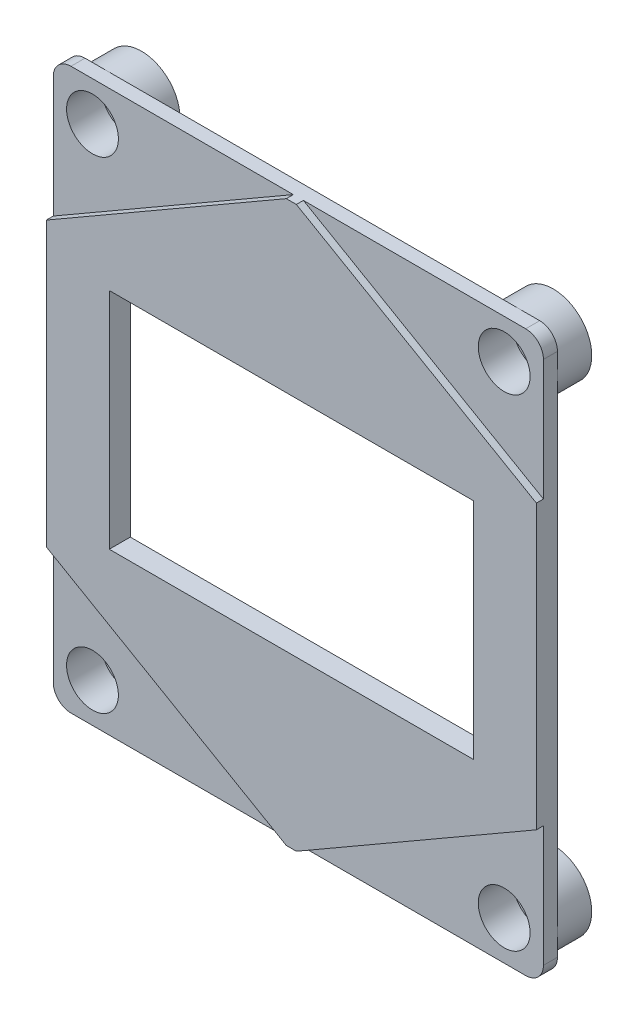
from build123d import *

# Parameters (mm, degrees)
SKETCH_1_W                = 35
SKETCH_1_H                = 40
EXTRUDE_1_DEPTH           = 1
SKETCH_2_R                = 2.75
EXTRUDE_2_DEPTH           = 2.5
SKETCH_3_R                = 1.85
CUT_EXTRUDE_1_DEPTH       = 2.5
SKETCH_4_R                = 1.1
CUT_EXTRUDE_2_DEPTH       = 2
FILLET_1_R                = 1.265
MIRROR_9_COPY_1_SKETCH_R  = 2.75
MIRROR_9_COPY_1_DEPTH     = 2.5
MIRROR_11_COPY_1_SKETCH_R = 1.1
MIRROR_11_COPY_1_DEPTH    = 2
MIRROR_13_COPY_1_SKETCH_R = 1.85
MIRROR_13_COPY_1_DEPTH    = 2.5
SKETCH_5_W                = 26
SKETCH_5_H                = 16
CUT_EXTRUDE_3_DEPTH       = 5
EXTRUDE_16_DEPTH          = 0.5
SKETCH_11_W               = 26
SKETCH_11_H               = 16
CUT_EXTRUDE_4_DEPTH       = 5
CUT_EXTRUDE_5_DEPTH       = 5


with BuildPart() as part:
    # 草图1 → 凸台-拉伸1 (new body)
    with BuildSketch(Plane.XY):
        Rectangle(SKETCH_1_W, SKETCH_1_H)
    extrude(amount=EXTRUDE_1_DEPTH)

    # 草图2 → 凸台-拉伸2 (add)
    with BuildSketch(Plane(origin=(0, 0, 0), x_dir=(-1, 0, 0), z_dir=(0, 0, -1))):
        with Locations((-14.7, 17.2)):
            Circle(SKETCH_2_R)
    extrude_2 = extrude(amount=EXTRUDE_2_DEPTH)

    # 草图3 → 切除-拉伸1 (cut)
    with BuildSketch(Plane.XY.offset(1)):
        with Locations((14.7, 17.2)):
            Circle(SKETCH_3_R)
    cut_extrude_1 = extrude(amount=-CUT_EXTRUDE_1_DEPTH, mode=Mode.SUBTRACT)

    # 草图4 → 切除-拉伸2 (cut, symmetric)
    with BuildSketch(Plane(origin=(0, 0, -2.5), x_dir=(-1, 0, 0), z_dir=(0, 0, -1))):
        with Locations((-14.7, 17.2)):
            Circle(SKETCH_4_R)
    cut_extrude_2 = extrude(amount=CUT_EXTRUDE_2_DEPTH, both=True, mode=Mode.SUBTRACT)

    # 圆角1
    fillet_1_edges = [part.edges().sort_by_distance(p)[0] for p in [
        (-17.5, 20, 0.5),
        (17.5, 20, 0.5),
        (17.5, -20, 0.5),
        (-17.5, -20, 0.5),
    ]]
    fillet(fillet_1_edges, radius=FILLET_1_R)

    # 镜向8: 凸台-拉伸2 across plane
    add(extrude_2.mirror(Plane(origin=(0, 0, 0), x_dir=(0, 0, 1), z_dir=(1, 0, 0))))

    # 镜向9: 凸台-拉伸2 across plane
    add(extrude_2.mirror(Plane.ZX))

    # 镜向9 copy 1 sketch → 镜向9 copy 1 (add)
    with BuildSketch(Plane(origin=(0, 0, 0), x_dir=(1, 0, 0), z_dir=(0, 0, -1))):
        with Locations((-14.7, 17.2)):
            Circle(MIRROR_9_COPY_1_SKETCH_R)
    extrude(amount=MIRROR_9_COPY_1_DEPTH)

    # 镜向10: 切除-拉伸2 across plane
    add(cut_extrude_2.mirror(Plane.ZX), mode=Mode.SUBTRACT)

    # 镜向11: 切除-拉伸2 across plane
    add(cut_extrude_2.mirror(Plane(origin=(0, 0, 0), x_dir=(0, 0, 1), z_dir=(1, 0, 0))), mode=Mode.SUBTRACT)

    # 镜向11 copy 1 sketch → 镜向11 copy 1 (cut, symmetric)
    with BuildSketch(Plane(origin=(0, 0, -2.5), x_dir=(1, 0, 0), z_dir=(0, 0, -1))):
        with Locations((-14.7, 17.2)):
            Circle(MIRROR_11_COPY_1_SKETCH_R)
    extrude(amount=MIRROR_11_COPY_1_DEPTH, both=True, mode=Mode.SUBTRACT)

    # 镜向12: 切除-拉伸1 across plane
    add(cut_extrude_1.mirror(Plane(origin=(0, 0, 0), x_dir=(0, 0, 1), z_dir=(1, 0, 0))), mode=Mode.SUBTRACT)

    # 镜向13: 切除-拉伸1 across plane
    add(cut_extrude_1.mirror(Plane.ZX), mode=Mode.SUBTRACT)

    # 镜向13 copy 1 sketch → 镜向13 copy 1 (cut)
    with BuildSketch(Plane(origin=(0, 0, 1), x_dir=(-1, 0, 0), z_dir=(0, 0, 1))):
        with Locations((14.7, 17.2)):
            Circle(MIRROR_13_COPY_1_SKETCH_R)
    extrude(amount=-MIRROR_13_COPY_1_DEPTH, mode=Mode.SUBTRACT)

    # 草图5 → 切除-拉伸3 (cut, symmetric)
    with BuildSketch(Plane.XY.offset(1)):
        Rectangle(SKETCH_5_W, SKETCH_5_H)
    extrude(amount=CUT_EXTRUDE_3_DEPTH, both=True, mode=Mode.SUBTRACT)

    # 草图10 → 凸台-拉伸16 (add)
    with BuildSketch(Plane.XY.offset(1)):
        Polygon((0, 20.207259422), (-17.5, 10.103629711), (-17.5, -10.103629711), (0, -20.207259422), (17.5, -10.103629711), (17.5, 10.103629711), align=None)
    extrude(amount=EXTRUDE_16_DEPTH)

    # 草图11 → 切除-拉伸4 (cut)
    with BuildSketch(Plane(origin=(0, 0, 1), x_dir=(-1, 0, 0), z_dir=(0, 0, -1))):
        Rectangle(SKETCH_11_W, SKETCH_11_H)
    extrude(amount=-CUT_EXTRUDE_4_DEPTH, mode=Mode.SUBTRACT)

    # 草图12 → 切除-拉伸5 (cut)
    with BuildSketch(Plane(origin=(0, 0, 1), x_dir=(-1, 0, 0), z_dir=(0, 0, -1))):
        Polygon((-0.358983849, 20), (0.358983849, 20), (0, 20.207259422), align=None)
    cut_extrude_5 = extrude(amount=-CUT_EXTRUDE_5_DEPTH, mode=Mode.SUBTRACT)

    # 镜向15: 切除-拉伸5 across plane
    add(cut_extrude_5.mirror(Plane.ZX), mode=Mode.SUBTRACT)


solid = part.part
